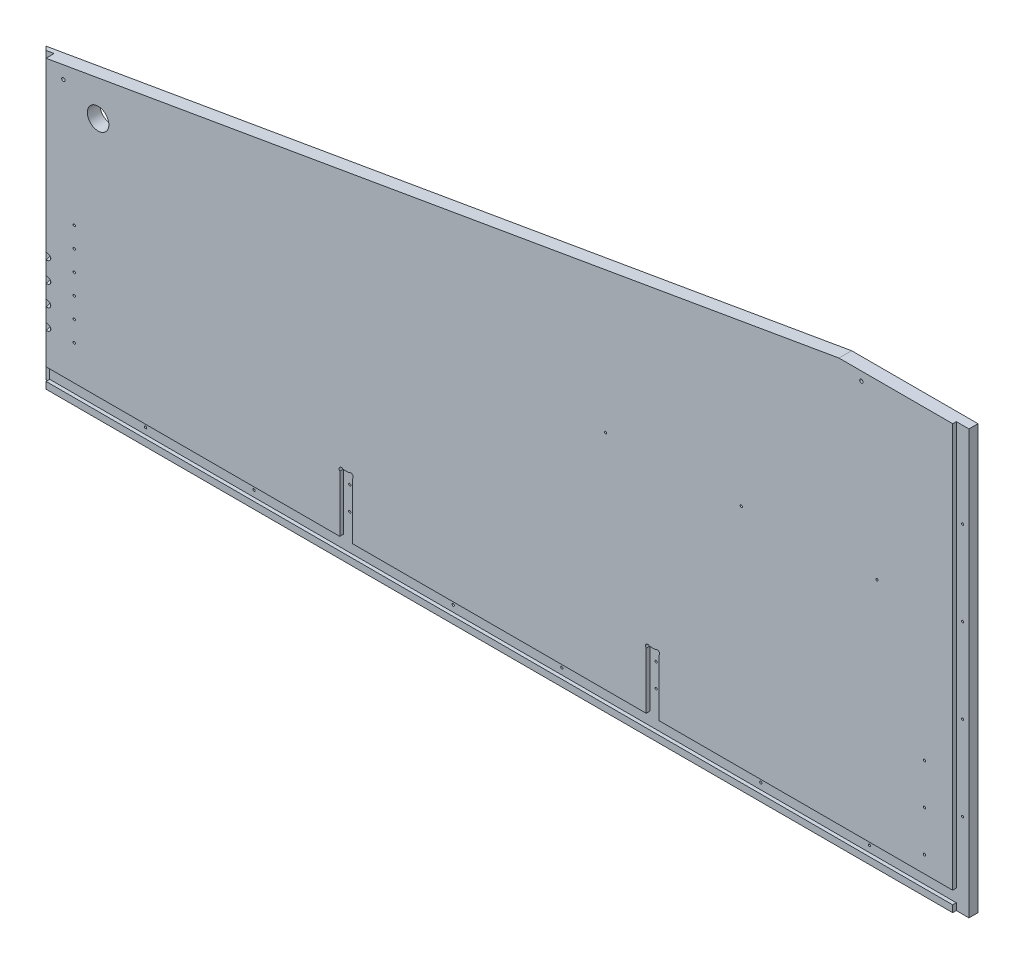
from build123d import *

# Parameters (mm, degrees)
CABSIDELEFT_THICKNESS_DEPTH = 17.78
LEDGECUTS_DEPTH_DEPTH       = 5.08
CABFRONTLEDGECUT_W          = 17.78
CABFRONTLEDGECUT_H          = 402.324113577
FRONTLEDGECUT_DEPTH_DEPTH   = 11.43
SKETCH5_R                   = 15.08125
SKETCH5_R_2                 = 1.5875
CUT_EXTRUDE3_DEPTH          = 17.78
SKETCH6_R                   = 3.302
CUT_EXTRUDE4_DEPTH          = 5.08
CUT_EXTRUDE5_DEPTH          = 594.36
SKETCH8_R                   = 2.38125
CUT_EXTRUDE6_DEPTH          = 17.78
SKETCH9_R                   = 1.5875
CUT_EXTRUDE7_DEPTH          = 12.7
SKETCH10_R                  = 4.7625
CUT_EXTRUDE8_DEPTH          = 76.2
SKETCH11_R                  = 4.7625
CUT_EXTRUDE9_DEPTH          = 76.2


with BuildPart() as part:
    # CabSideLeft_Outline → CabSideLeft_Thickness (new body)
    with BuildSketch(Plane.XY):
        Polygon((10946.341666666, -4853.78125), (10946.341666666, -5253.0375), (12254.441666666, -5253.0375), (12254.441666666, -4658.6775), (12077.077955444, -4658.6775), align=None)
    extrude(amount=-CABSIDELEFT_THICKNESS_DEPTH)

    # CabSideLeft_LedgeCuts → LedgeCuts_Depth (cut)
    with BuildSketch(Plane.XY):
        Polygon((10946.341666666, -5225.7325), (10946.341666666, -5243.5125), (12236.661666666, -5243.5125), (12236.661666666, -5253.0375), (12254.441666666, -5253.0375), (12254.441666666, -4658.6775), (12236.661666666, -4658.6775), (12236.661666666, -5225.7325), (11824.335, -5225.7325), (11824.335, -5141.9125), (11806.555, -5141.9125), (11806.555, -5225.7325), (11394.228333334, -5225.7325), (11394.228333334, -5141.912499999), (11376.448333334, -5141.9125), (11376.448333334, -5225.7325), align=None)
    extrude(amount=-LEDGECUTS_DEPTH_DEPTH, mode=Mode.SUBTRACT)

    # CabFrontLedgeCut → FrontLedgeCut_Depth (cut)
    with BuildSketch(Plane.XY):
        with Locations((10955.231666666, -5051.875443212)):
            Rectangle(CABFRONTLEDGECUT_W, CABFRONTLEDGECUT_H)
    extrude(amount=-FRONTLEDGECUT_DEPTH_DEPTH, mode=Mode.SUBTRACT)

    # Sketch5 → Cut-Extrude3 (cut)
    with BuildSketch(Plane.XY):
        with Locations((11037.231463428, -4887.549352662)):
            Circle(SKETCH5_R)
        with Locations((11003.796466666, -5033.9625)):
            Circle(SKETCH5_R_2)
        with Locations((10955.231666666, -4929.98125)):
            Circle(SKETCH5_R_2)
        with Locations((10955.231666666, -5031.58125)):
            Circle(SKETCH5_R_2)
        with Locations((11003.809166666, -5062.5375)):
            Circle(SKETCH5_R_2)
        with Locations((11003.809166666, -5119.6875)):
            Circle(SKETCH5_R_2)
        with Locations((11003.809166666, -5176.8375)):
            Circle(SKETCH5_R_2)
        with Locations((11251.141666666, -5234.6225)):
            Circle(SKETCH5_R_2)
        with Locations((11098.741666666, -5234.6225)):
            Circle(SKETCH5_R_2)
        with Locations((11385.338333334, -5160.9625)):
            Circle(SKETCH5_R_2)
        with Locations((11385.338333334, -5193.9825)):
            Circle(SKETCH5_R_2)
        with Locations((11530.541666666, -5234.6225)):
            Circle(SKETCH5_R_2)
        with Locations((11682.941666666, -5234.6225)):
            Circle(SKETCH5_R_2)
        with Locations((11815.445, -5160.9625)):
            Circle(SKETCH5_R_2)
        with Locations((11815.445, -5193.9825)):
            Circle(SKETCH5_R_2)
        with Locations((11962.341666666, -5234.6225)):
            Circle(SKETCH5_R_2)
        with Locations((12114.741666666, -5234.6225)):
            Circle(SKETCH5_R_2)
        with Locations((12196.974166666, -5202.2375)):
            Circle(SKETCH5_R_2)
        with Locations((12196.974166666, -5145.0875)):
            Circle(SKETCH5_R_2)
        with Locations((12245.551666666, -5134.504166666)):
            Circle(SKETCH5_R_2)
        with Locations((12196.974166666, -5087.9375)):
            Circle(SKETCH5_R_2)
        with Locations((12245.551666666, -5015.970833334)):
            Circle(SKETCH5_R_2)
        with Locations((12245.551666666, -4897.4375)):
            Circle(SKETCH5_R_2)
        with Locations((12245.551666666, -4778.904166666)):
            Circle(SKETCH5_R_2)
        with Locations((11003.796466666, -5091.1125)):
            Circle(SKETCH5_R_2)
        with Locations((11003.796466666, -5148.2625)):
            Circle(SKETCH5_R_2)
    extrude(amount=-CUT_EXTRUDE3_DEPTH, mode=Mode.SUBTRACT)

    # Sketch6 → Cut-Extrude4 (cut)
    with BuildSketch(Plane.XY):
        with Locations((11378.693397364, -5144.15756403)):
            Circle(SKETCH6_R)
        with Locations((11391.983269304, -5144.157564029)):
            Circle(SKETCH6_R)
        with Locations((11808.80006403, -5144.15756403)):
            Circle(SKETCH6_R)
        with Locations((11822.08993597, -5144.15756403)):
            Circle(SKETCH6_R)
    extrude(amount=-CUT_EXTRUDE4_DEPTH, mode=Mode.SUBTRACT)

    # FrontBevelCut → Cut-Extrude5 (cut)
    with BuildSketch(Plane.XZ.offset(5253.0375)):
        Polygon((10946.341666666, -17.78), (10946.341666666, -11.43), (10952.691666666, -11.43), align=None)
    extrude(amount=-CUT_EXTRUDE5_DEPTH, mode=Mode.SUBTRACT)

    # Sketch8 → Cut-Extrude6 (cut)
    with BuildSketch(Plane(origin=(0, 0, -17.78), x_dir=(-1, 0, 0), z_dir=(0, 0, -1))):
        with Locations((-10988.502040274, -4864.401180469)):
            Circle(SKETCH8_R)
        with Locations((-12108.60052224, -4671.132938908)):
            Circle(SKETCH8_R)
    extrude(amount=-CUT_EXTRUDE6_DEPTH, mode=Mode.SUBTRACT)

    # Sketch9 → Cut-Extrude7 (cut)
    with BuildSketch(Plane.XY):
        with Locations((12130.320157336, -4901.492108659)):
            Circle(SKETCH9_R)
        with Locations((11939.909008281, -4907.309695425)):
            Circle(SKETCH9_R)
        with Locations((11749.497859227, -4913.127282192)):
            Circle(SKETCH9_R)
    extrude(amount=-CUT_EXTRUDE7_DEPTH, mode=Mode.SUBTRACT)

    # Sketch10 → Cut-Extrude8 (cut)
    with BuildSketch(Plane(origin=(5498.144384557, 0, 5498.144384557), x_dir=(0.707106781, 0, -0.707106781), z_dir=(0.707106781, 0, 0.707106781))):
        with Locations((7752.804780254, -5119.6875)):
            Circle(SKETCH10_R)
        with Locations((7752.804780254, -5176.8375)):
            Circle(SKETCH10_R)
    extrude(amount=-CUT_EXTRUDE8_DEPTH, mode=Mode.SUBTRACT)

    # Sketch11 → Cut-Extrude9 (cut)
    with BuildSketch(Plane(origin=(5498.150734557, 0, 5498.150734557), x_dir=(0.707106781, 0, -0.707106781), z_dir=(0.707106781, 0, 0.707106781))):
        with Locations((7752.795799998, -5091.1125)):
            Circle(SKETCH11_R)
        with Locations((7752.795799998, -5148.2625)):
            Circle(SKETCH11_R)
    extrude(amount=-CUT_EXTRUDE9_DEPTH, mode=Mode.SUBTRACT)


solid = part.part
